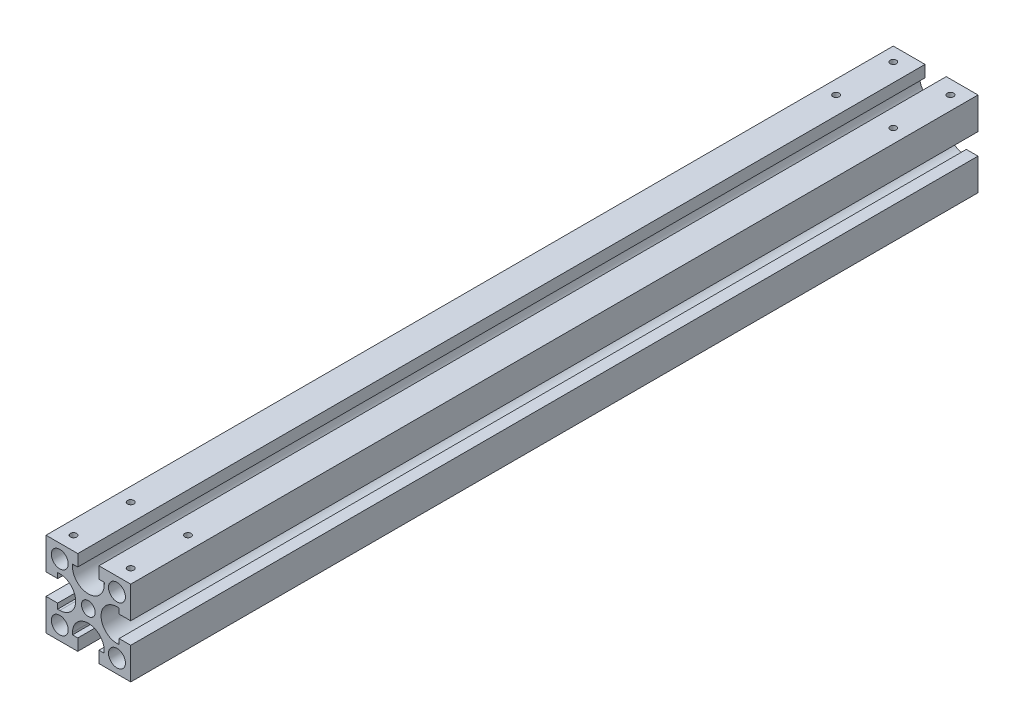
from build123d import *

# Parameters (mm, degrees)
SKETCH_1_W           = 40
SKETCH_1_H           = 40
EXTRUDE_1_DEPTH      = 400
SKETCH_2_R           = 3.25
SKETCH_2_R_2         = 4
CUT_EXTRUDE_1_DEPTH  = 401
M3X0_5_2_D           = 2.5
M3X0_5_2_DEPTH       = 7.5
M3X0_5_2_CBORE_D     = 3
M3X0_5_2_CBORE_DEPTH = 6
M3X0_5_2_TIP         = 0.751075774


with BuildPart() as part:
    # 草圖1 → 伸長1 (new body)
    with BuildSketch(Plane.XY):
        Rectangle(SKETCH_1_W, SKETCH_1_H)
    extrude(amount=EXTRUDE_1_DEPTH)

    # 草圖2 → 除料-伸長1 (cut, through all)
    with BuildSketch(Plane(origin=(0, 0, 0), x_dir=(-1, 0, 0), z_dir=(0, 0, -1))):
        Circle(SKETCH_2_R)
        with Locations((-13.5, 13.5)):
            Circle(SKETCH_2_R_2)
        with Locations((13.5, 13.5)):
            Circle(SKETCH_2_R_2)
        with Locations((-13.5, -13.5)):
            Circle(SKETCH_2_R_2)
        with Locations((13.5, -13.5)):
            Circle(SKETCH_2_R_2)
        with BuildLine():
            Line((5, 14.5), (7.5, 14.5))
            Line((7.5, 14.5), (7.5, 13.5))
            ThreePointArc((7.5, 13.5), (0, 6), (-7.5, 13.5))
            Line((-7.5, 13.5), (-7.5, 14.5))
            Line((-7.5, 14.5), (-5, 14.5))
            Line((-5, 14.5), (-5, 20))
            Line((-5, 20), (5, 20))
            Line((5, 20), (5, 14.5))
        make_face()
        with BuildLine():
            Line((14.5, -5), (14.5, -7.5))
            Line((14.5, -7.5), (13.5, -7.5))
            ThreePointArc((13.5, -7.5), (6, 0), (13.5, 7.5))
            Line((13.5, 7.5), (14.5, 7.5))
            Line((14.5, 7.5), (14.5, 5))
            Line((14.5, 5), (20, 5))
            Line((20, 5), (20, -5))
            Line((20, -5), (14.5, -5))
        make_face()
        with BuildLine():
            Line((-5, -14.5), (-7.5, -14.5))
            Line((-7.5, -14.5), (-7.5, -13.5))
            ThreePointArc((-7.5, -13.5), (0, -6), (7.5, -13.5))
            Line((7.5, -13.5), (7.5, -14.5))
            Line((7.5, -14.5), (5, -14.5))
            Line((5, -14.5), (5, -20))
            Line((5, -20), (-5, -20))
            Line((-5, -20), (-5, -14.5))
        make_face()
        with BuildLine():
            Line((-14.5, 5), (-14.5, 7.5))
            Line((-14.5, 7.5), (-13.5, 7.5))
            ThreePointArc((-13.5, 7.5), (-6, 0), (-13.5, -7.5))
            Line((-13.5, -7.5), (-14.5, -7.5))
            Line((-14.5, -7.5), (-14.5, -5))
            Line((-14.5, -5), (-20, -5))
            Line((-20, -5), (-20, 5))
            Line((-20, 5), (-14.5, 5))
        make_face()
    extrude(amount=-CUT_EXTRUDE_1_DEPTH, mode=Mode.SUBTRACT)

    # M3x0.5 螺紋孔2
    with Locations(Plane(origin=(0, 20, 0), x_dir=(1, 0, 0), z_dir=(0, 1, 0))):
        with Locations((-13.5, -6.5), (-13.5, -33.5), (-13.5, -393.5), (-13.5, -366.5), (13.5, -366.5), (13.5, -393.5), (13.5, -33.5), (13.5, -6.5)):
            CounterBoreHole(M3X0_5_2_D / 2, M3X0_5_2_CBORE_D / 2, M3X0_5_2_CBORE_DEPTH, depth=M3X0_5_2_DEPTH)
            with Locations((0, 0, -(M3X0_5_2_DEPTH + M3X0_5_2_TIP / 2))):  # 118° drill point
                Cone(0, M3X0_5_2_D / 2, M3X0_5_2_TIP, mode=Mode.SUBTRACT)


solid = part.part
